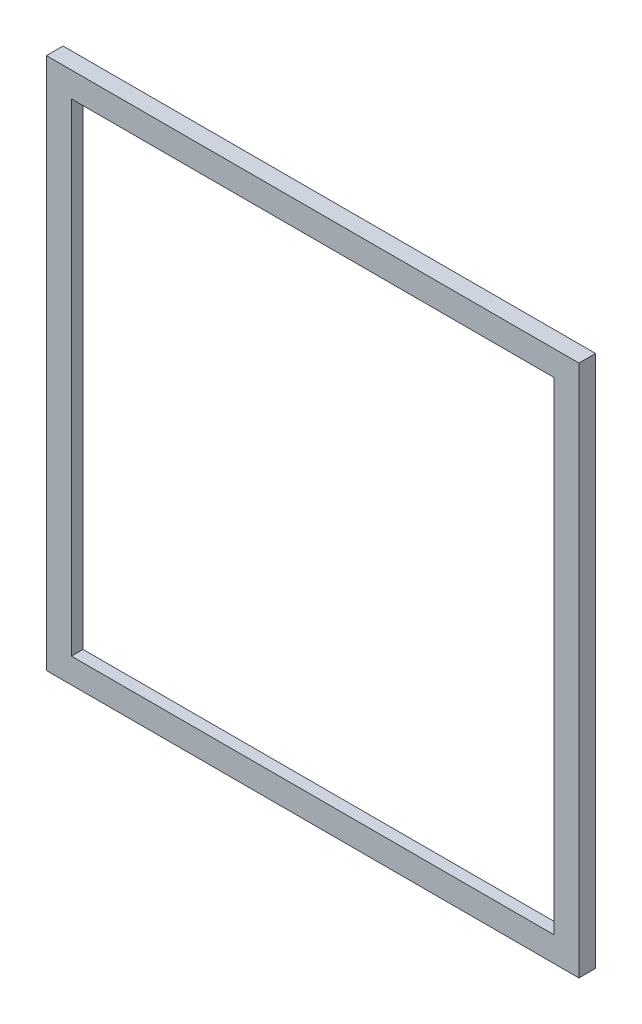
from build123d import *

# Parameters (mm, degrees)
CROQUIS1_W              = 320
CROQUIS1_H              = 320
CROQUIS1_W_2            = 290
CROQUIS1_H_2            = 290
SALIENTE_EXTRUIR1_DEPTH = 10
CROQUIS2_W              = 300
CROQUIS2_H              = 300
CORTAR_EXTRUIR1_DEPTH   = 3


with BuildPart() as part:
    # Croquis1 → Saliente-Extruir1 (new body)
    with BuildSketch(Plane.XY):
        with Locations((150, 150)):
            Rectangle(CROQUIS1_W, CROQUIS1_H)
        with Locations((150, 150)):
            Rectangle(CROQUIS1_W_2, CROQUIS1_H_2, mode=Mode.SUBTRACT)
    extrude(amount=SALIENTE_EXTRUIR1_DEPTH)

    # Croquis2 → Cortar-Extruir1 (cut)
    with BuildSketch(Plane(origin=(0, 0, 0), x_dir=(-1, 0, 0), z_dir=(0, 0, -1))):
        with Locations((-150, 150)):
            Rectangle(CROQUIS2_W, CROQUIS2_H)
    extrude(amount=-CORTAR_EXTRUIR1_DEPTH, mode=Mode.SUBTRACT)


solid = part.part
